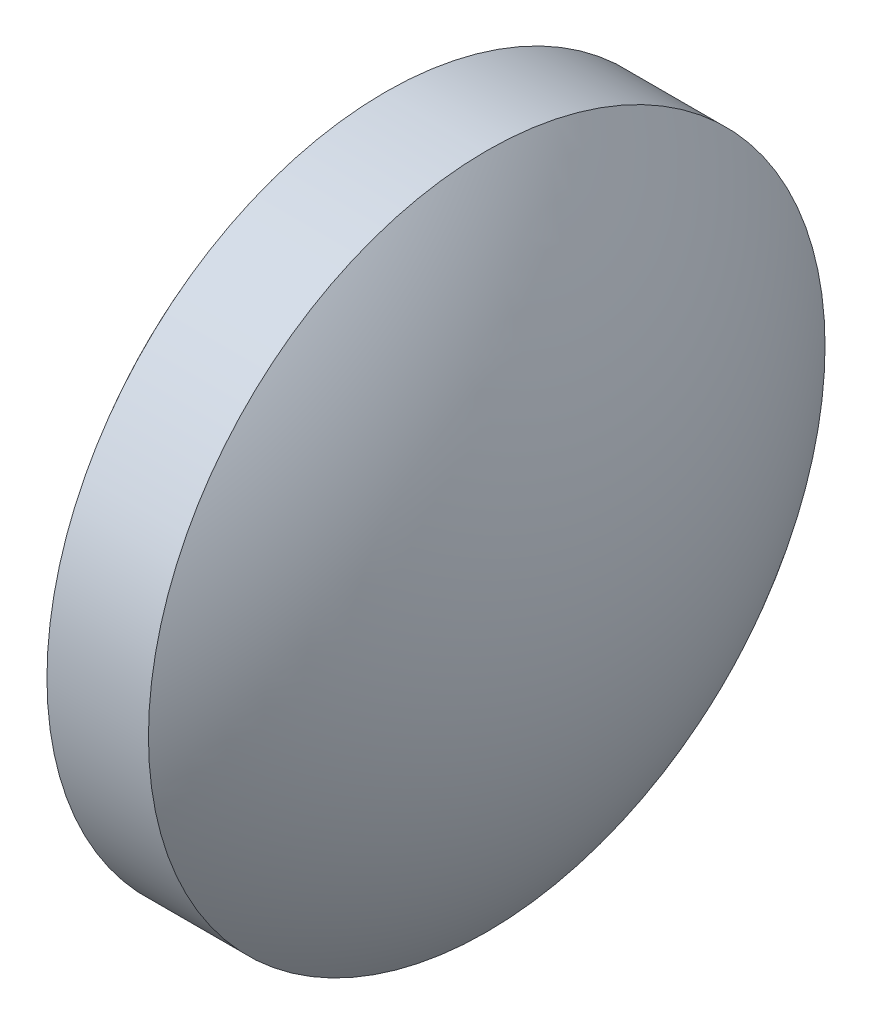
from build123d import *

# Parameters (mm, degrees)
SKETCH_1_ONE_SIDE_W = 1.5
SKETCH_1_ONE_SIDE_H = 5


with BuildPart() as part:
    # 草图1 one side → 旋转1 (revolve)
    with BuildSketch(Plane.XY):
        with Locations((34.038658966, 21.640201978)):
            Rectangle(SKETCH_1_ONE_SIDE_W, SKETCH_1_ONE_SIDE_H)
        with BuildLine():
            Line((31.623658966, 19.140201978), (33.288658966, 19.140201978))
            Line((33.288658966, 19.140201978), (33.288658966, 24.140201978))
            ThreePointArc((33.288658966, 24.140201978), (32.05084972, 21.775169957), (31.623658966, 19.140201978))
        make_face()
        with BuildLine():
            Line((34.788658966, 19.140201978), (36.453658966, 19.140201978))
            ThreePointArc((36.453658966, 19.140201978), (36.026468212, 21.775169957), (34.788658966, 24.140201978))
            Line((34.788658966, 24.140201978), (34.788658966, 19.140201978))
        make_face()
    revolve(axis=Axis((31.222598957, 19.140201978, 0), (1, 0, 0)))


solid = part.part
